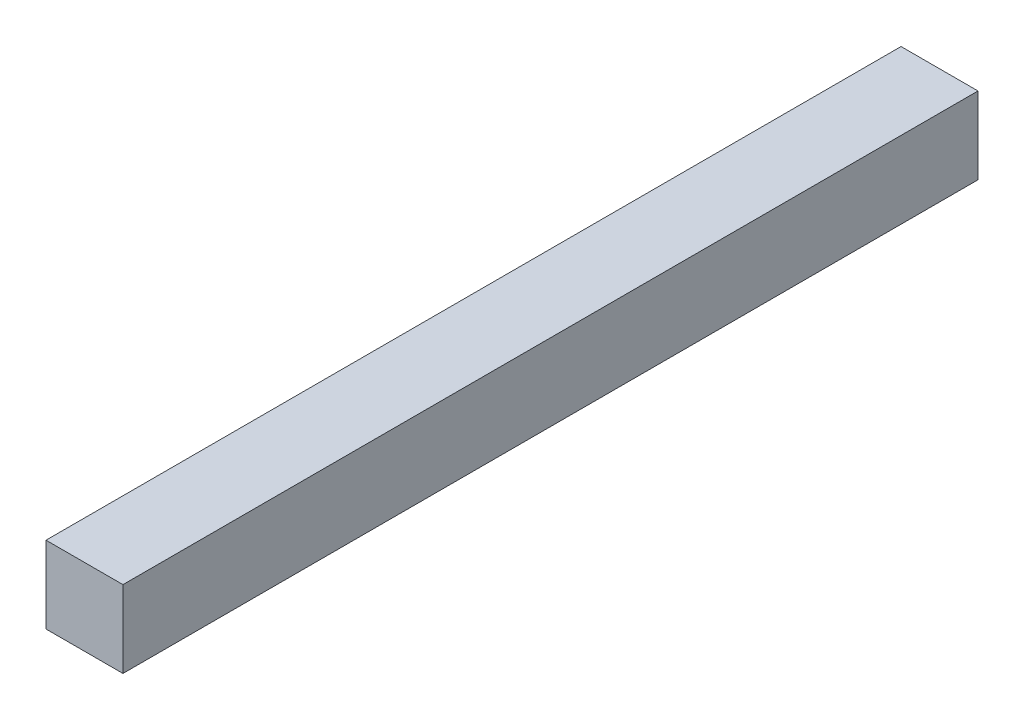
from build123d import *

# Parameters (mm, degrees)
SKETCH1_W           = 45
SKETCH1_H           = 45
BOSS_EXTRUDE1_DEPTH = 500


with BuildPart() as part:
    # Sketch1 → Boss-Extrude1 (new body)
    with BuildSketch(Plane.XY):
        with Locations((22.5, 22.5)):
            Rectangle(SKETCH1_W, SKETCH1_H)
    extrude(amount=BOSS_EXTRUDE1_DEPTH)


solid = part.part
